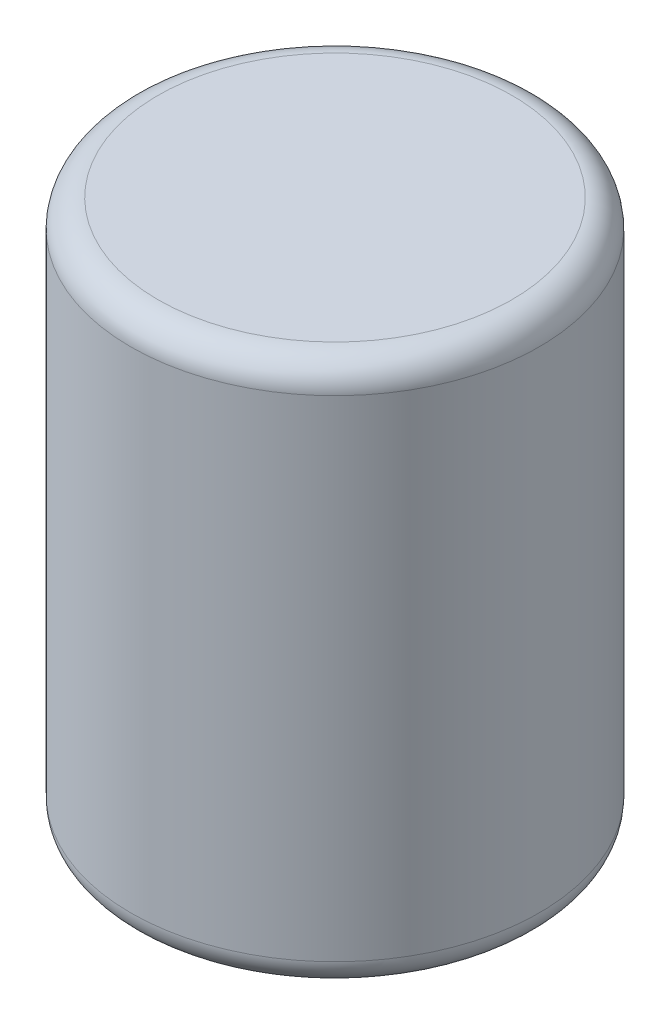
from build123d import *

# Parameters (mm, degrees)
ESBO_O1_R                = 750
RESSALTO_EXTRUS_O1_DEPTH = 2000
FILETE1_R                = 100


with BuildPart() as part:
    # Esboço1 → Ressalto-extrusão1 (new body)
    with BuildSketch(Plane(origin=(0, 0, 0), x_dir=(1, 0, 0), z_dir=(0, 1, 0))):
        Circle(ESBO_O1_R)
    extrude(amount=RESSALTO_EXTRUS_O1_DEPTH)

    # Filete1
    filete1_edges = [part.edges().sort_by_distance(p)[0] for p in [
        (-750, 0, 0),
        (-750, 2000, 0),
    ]]
    fillet(filete1_edges, radius=FILETE1_R)


solid = part.part
